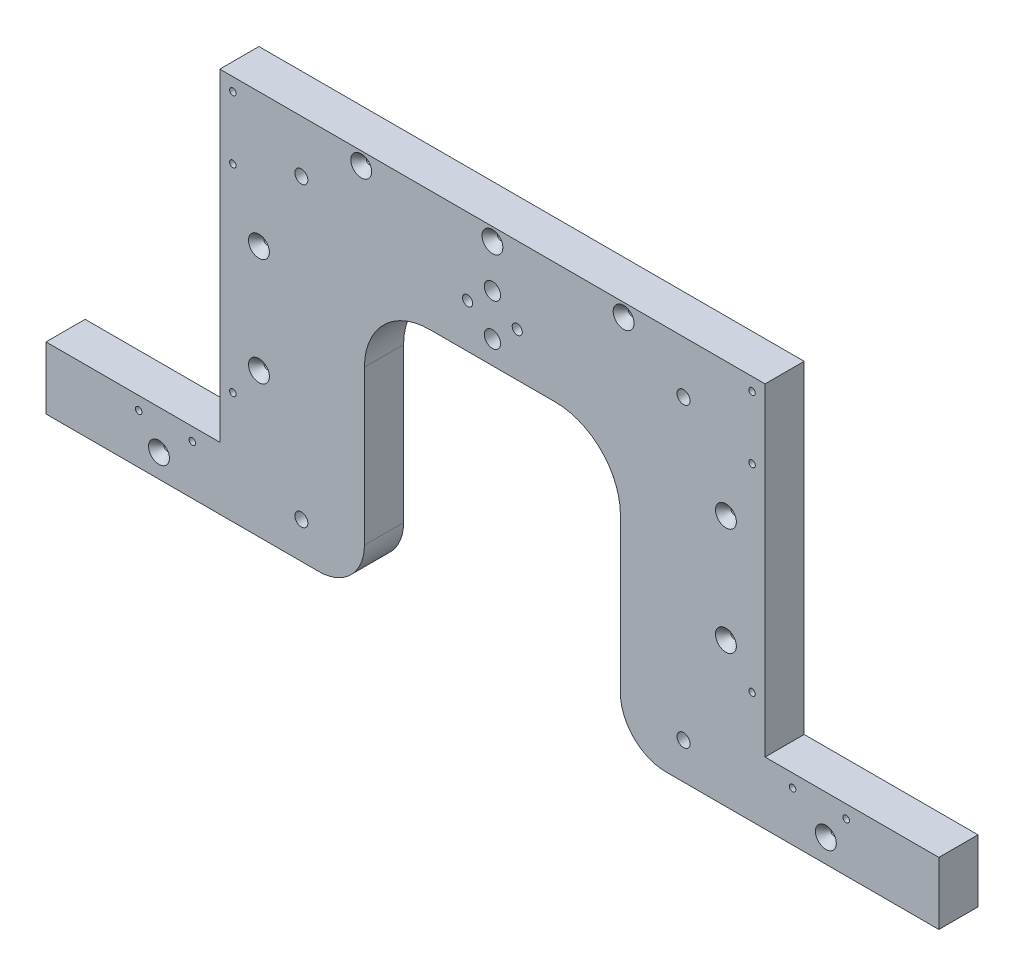
from build123d import *

# Parameters (mm, degrees)
BOSS_EXTRUDE2_DEPTH            = 19.05
FILLET1_R                      = 22.225
FILLET2_R                      = 31.75
SKETCH6_W                      = 19.05
SKETCH6_H                      = 157.3
BOSS_EXTRUDE3_DEPTH            = 12.7
FILLET1_OF_MIRROR1_R           = 22.225
FILLET2_OF_MIRROR1_R           = 31.75
F_5_16_0_3125_DIAMETER_HOLE1_D = 7.9375
F_8_CLEARANCE_HOLE1_D          = 4.9149
HOLE1_D                        = 3.175
HOLE1_DEPTH                    = 31.75
HOLE1_CSINK_D                  = 10.16
HOLE1_CSINK_ANGLE              = 82
HOLE1_TIP                      = 0.953866233
HOLE2_D                        = 3.175
HOLE2_DEPTH                    = 31.75
HOLE2_CSINK_D                  = 10.16
HOLE2_CSINK_ANGLE              = 82
HOLE2_TIP                      = 0.953866233
F_1_4_0_25_DIAMETER_HOLE1_D    = 6.35


with BuildPart() as part:
    # Sketch1 → Boss-Extrude2 (new body)
    with BuildSketch(Plane.XY):
        Polygon((-341.304465963, -157.3), (-341.304465963, -175), (-186.304465963, -175), (-186.304465963, -46), (-124.004465969, -46), (-124.004465969, 12.7), (-244.004465963, 12.7), (-244.004465963, -144.6), (-341.304465963, -144.6), align=None)
    boss_extrude2 = extrude(amount=BOSS_EXTRUDE2_DEPTH)

    # Fillet1
    fillet1_edges = [part.edges().sort_by_distance(p)[0] for p in [
        (-186.304465963, -175, 9.525),
    ]]
    fillet(fillet1_edges, radius=FILLET1_R)

    # Fillet2
    fillet2_edges = [part.edges().sort_by_distance(p)[0] for p in [
        (-186.304465963, -46, 9.525),
    ]]
    fillet(fillet2_edges, radius=FILLET2_R)

    # Sketch6 → Boss-Extrude3 (add)
    with BuildSketch(Plane.ZY.offset(244.004465963)):
        with Locations((9.525, -65.95)):
            Rectangle(SKETCH6_W, SKETCH6_H)
    boss_extrude3 = extrude(amount=BOSS_EXTRUDE3_DEPTH)

    # Mirror1: Boss-Extrude2, Boss-Extrude3 across plane
    add(boss_extrude2.mirror(Plane(origin=(-124.004465969, 12.7, 19.05), x_dir=(0, 0, 1), z_dir=(1, 0, 0))))
    add(boss_extrude3.mirror(Plane(origin=(-124.004465969, 12.7, 19.05), x_dir=(0, 0, 1), z_dir=(1, 0, 0))))

    # Fillet1 of Mirror1
    fillet1_of_mirror1_edges = [part.edges().sort_by_distance(p)[0] for p in [
        (-61.704465975, -175, 9.525),
    ]]
    fillet(fillet1_of_mirror1_edges, radius=FILLET1_OF_MIRROR1_R)

    # Fillet2 of Mirror1
    fillet2_of_mirror1_edges = [part.edges().sort_by_distance(p)[0] for p in [
        (-61.704465975, -46, 9.525),
    ]]
    fillet(fillet2_of_mirror1_edges, radius=FILLET2_OF_MIRROR1_R)

    # 5/16 (0.3125) Diameter Hole1 (through all)
    with Locations(Plane(origin=(0, 0, 0), x_dir=(-1, 0, 0), z_dir=(0, 0, -1))):
        with Locations((124.004465969, -34.7475), (124.004465969, -14.4275)):
            Hole(F_5_16_0_3125_DIAMETER_HOLE1_D / 2)

    # #8 Clearance Hole1 (through all)
    with Locations(Plane.XY.offset(19.05)):
        with Locations((-111.927249911, -24.5875), (-136.081682027, -24.5875)):
            Hole(F_8_CLEARANCE_HOLE1_D / 2)

    # Hole1
    with Locations(Plane(origin=(-124.004465969, -155.024290059, 19.05), x_dir=(1, 0, 0), z_dir=(0, 0, 1))):
        with Locations((-162.299999994, -8.625709941), (-113.649999994, 50.157623392), (-113.649999994, 102.590956725), (162.299999994, -8.625709941), (113.649999994, 50.157623392), (113.649999994, 102.590956725), (63.85, 161.374290059), (0, 161.374290059), (-63.85, 161.374290059)):
            CounterSinkHole(HOLE1_D / 2, HOLE1_CSINK_D / 2, depth=HOLE1_DEPTH, counter_sink_angle=HOLE1_CSINK_ANGLE)
            with Locations((0, 0, -(HOLE1_DEPTH + HOLE1_TIP / 2))):  # 118° drill point
                Cone(0, HOLE1_D / 2, HOLE1_TIP, mode=Mode.SUBTRACT)

    # Hole2
    with Locations(Plane(origin=(-124.004465969, -155.024290059, 0), x_dir=(-1, 0, 0), z_dir=(0, 0, -1))):
        with Locations((126.349999994, 161.374290059), (146.083333327, 4.074290059), (172.166666661, 4.074290059), (126.349999994, 34.524290059), (126.349999994, 130.924290059), (-172.166666661, 4.074290059), (-146.083333327, 4.074290059), (-126.349999994, 34.524290059), (-126.349999994, 130.924290059), (-126.349999994, 161.374290059)):
            CounterSinkHole(HOLE2_D / 2, HOLE2_CSINK_D / 2, depth=HOLE2_DEPTH, counter_sink_angle=HOLE2_CSINK_ANGLE)
            with Locations((0, 0, -(HOLE2_DEPTH + HOLE2_TIP / 2))):  # 118° drill point
                Cone(0, HOLE2_D / 2, HOLE2_TIP, mode=Mode.SUBTRACT)

    # 1/4 (0.25) Diameter Hole1 (through all)
    with Locations(Plane.XY.offset(19.05)):
        with Locations((-217.016965963, -157.3), (-217.016965963, -12.7), (-30.991965975, -12.7), (-30.991965975, -157.3)):
            Hole(F_1_4_0_25_DIAMETER_HOLE1_D / 2)


solid = part.part
